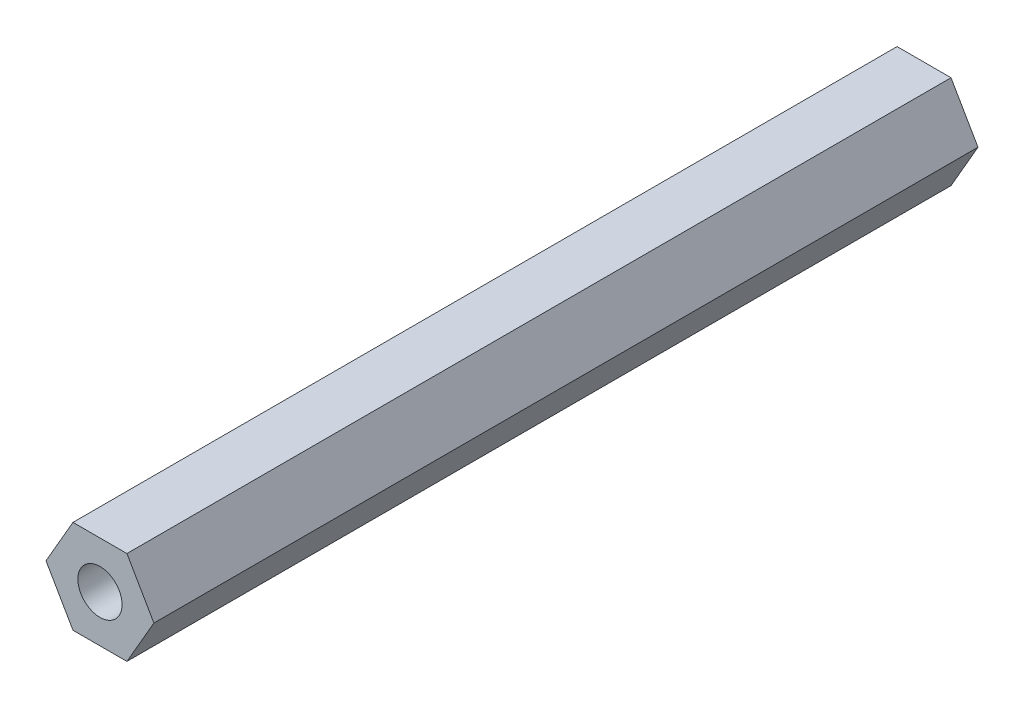
from build123d import *

# Parameters (mm, degrees)
CROQUIS1_R              = 1.5
SALIENTE_EXTRUIR1_DEPTH = 56


with BuildPart() as part:
    # Croquis1 → Saliente-Extruir1 (new body)
    with BuildSketch(Plane.XY):
        Polygon((3.666174209, 0), (1.833087105, 3.175), (-1.833087105, 3.175), (-3.666174209, 0), (-1.833087105, -3.175), (1.833087105, -3.175), align=None)
        Circle(CROQUIS1_R, mode=Mode.SUBTRACT)
    extrude(amount=SALIENTE_EXTRUIR1_DEPTH)


solid = part.part
